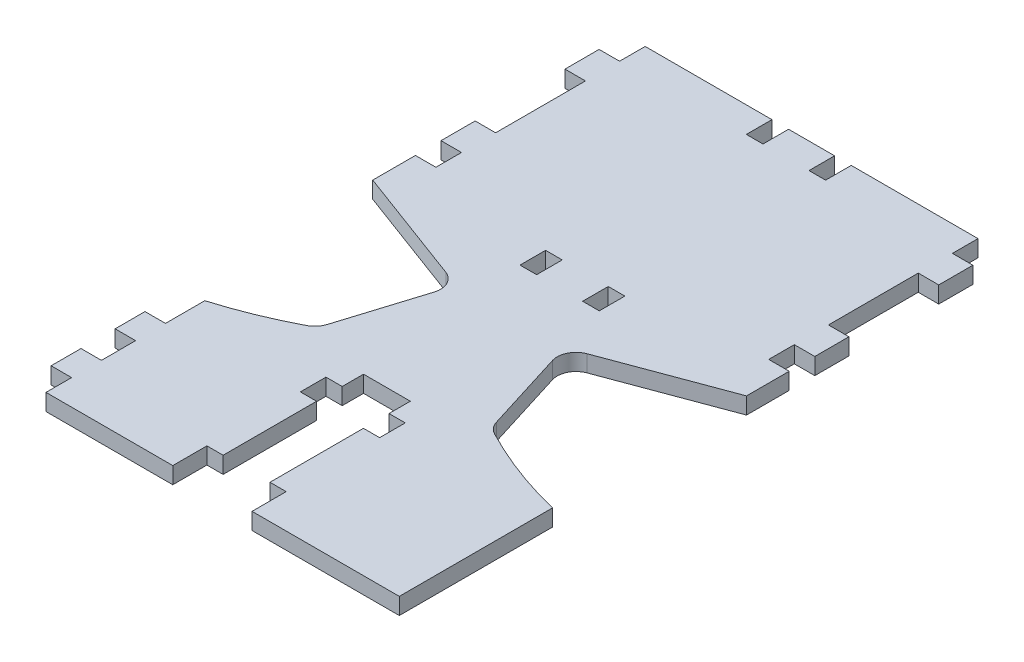
from build123d import *

# Parameters (mm, degrees)
SKETCH1_W           = 4.953
SKETCH1_H           = 7.62
BOSS_EXTRUDE1_DEPTH = 2.4765


with BuildPart() as part:
    # Sketch1 → Boss-Extrude1 (new, symmetric)
    with BuildSketch(Plane(origin=(0, 0, 0), x_dir=(1, 0, 0), z_dir=(0, 1, 0))):
        with BuildLine():
            Line((-49.53, 45.72), (-11.7983, 45.72))
            Line((-11.7983, 45.72), (-11.7983, 38.1))
            Line((-11.7983, 38.1), (-6.8453, 38.1))
            Line((-6.8453, 38.1), (-6.8453, 45.72))
            Line((-6.8453, 45.72), (6.8453, 45.72))
            Line((6.8453, 45.72), (6.8453, 38.1))
            Line((6.8453, 38.1), (11.7983, 38.1))
            Line((11.7983, 38.1), (11.7983, 45.72))
            Line((11.7983, 45.72), (49.53, 45.72))
            Line((49.53, 45.72), (49.53, 38.1))
            Line((49.53, 38.1), (55.626, 38.1))
            Line((55.626, 38.1), (55.626, 27.94))
            Line((55.626, 27.94), (49.53, 27.94))
            Line((49.53, 27.94), (49.53, 1.208143374))
            Line((49.53, 1.208143374), (55.626, 1.208143374))
            Line((55.626, 1.208143374), (55.626, -8.951856626))
            Line((55.626, -8.951856626), (49.53, -8.951856626))
            Line((49.53, -8.951856626), (49.53, -16.571856626))
            Line((49.53, -16.571856626), (55.626, -16.571856626))
            Line((55.626, -16.571856626), (55.626, -29.271856626))
            Line((55.626, -29.271856626), (21.019827136, -42.136821893))
            ThreePointArc((21.019827136, -42.136821893), (17.95098831, -44.911778638), (17.631953735, -49.036869377))
            Line((17.631953735, -49.036869377), (25.187729856, -73.287029113))
            ThreePointArc((25.187729856, -73.287029113), (26.234780075, -75.207903536), (27.939063878, -76.579577488))
            ThreePointArc((27.939063878, -76.579577488), (41.468907088, -82.632484358), (55.626, -87.022365809))
            Line((55.626, -87.022365809), (55.626, -132.617292876))
            Line((55.626, -132.617292876), (11.7983, -132.617292876))
            Line((11.7983, -132.617292876), (11.7983, -122.457292876))
            Line((11.7983, -122.457292876), (6.9723, -122.457292876))
            Line((6.9723, -122.457292876), (6.9723, -94.642365809))
            Line((6.9723, -94.642365809), (11.7983, -94.642365809))
            Line((11.7983, -94.642365809), (11.7983, -87.022365809))
            Line((11.7983, -87.022365809), (6.9723, -87.022365809))
            Line((6.9723, -87.022365809), (6.9723, -80.672365809))
            Line((6.9723, -80.672365809), (-6.9723, -80.672365809))
            Line((-6.9723, -80.672365809), (-6.9723, -87.022365809))
            Line((-6.9723, -87.022365809), (-11.7983, -87.022365809))
            Line((-11.7983, -87.022365809), (-11.7983, -94.642365809))
            Line((-11.7983, -94.642365809), (-6.9723, -94.642365809))
            Line((-6.9723, -94.642365809), (-6.9723, -122.457292876))
            Line((-6.9723, -122.457292876), (-11.7983, -122.457292876))
            Line((-11.7983, -122.457292876), (-11.7983, -132.617292876))
            Line((-11.7983, -132.617292876), (-49.53, -132.617292876))
            Line((-49.53, -132.617292876), (-49.53, -124.997292876))
            Line((-49.53, -124.997292876), (-55.626, -124.997292876))
            Line((-55.626, -124.997292876), (-55.626, -116.107292876))
            Line((-55.626, -116.107292876), (-49.53, -116.107292876))
            Line((-49.53, -116.107292876), (-49.53, -105.947292876))
            Line((-49.53, -105.947292876), (-55.626, -105.947292876))
            Line((-55.626, -105.947292876), (-55.626, -97.057292876))
            Line((-55.626, -97.057292876), (-49.53, -97.057292876))
            Line((-49.53, -97.057292876), (-49.53, -85.359826344))
            ThreePointArc((-49.53, -85.359826344), (-38.527111219, -81.479756652), (-27.939063878, -76.579577488))
            ThreePointArc((-27.939063878, -76.579577488), (-26.234780075, -75.207903536), (-25.187729856, -73.287029113))
            Line((-25.187729856, -73.287029113), (-17.631953735, -49.036869377))
            ThreePointArc((-17.631953735, -49.036869377), (-17.95098831, -44.911778638), (-21.019827136, -42.136821893))
            Line((-21.019827136, -42.136821893), (-55.626, -29.271856626))
            Line((-55.626, -29.271856626), (-55.626, -16.571856626))
            Line((-55.626, -16.571856626), (-49.53, -16.571856626))
            Line((-49.53, -16.571856626), (-49.53, -8.951856626))
            Line((-49.53, -8.951856626), (-55.626, -8.951856626))
            Line((-55.626, -8.951856626), (-55.626, 1.208143374))
            Line((-55.626, 1.208143374), (-49.53, 1.208143374))
            Line((-49.53, 1.208143374), (-49.53, 27.94))
            Line((-49.53, 27.94), (-55.626, 27.94))
            Line((-55.626, 27.94), (-55.626, 38.1))
            Line((-55.626, 38.1), (-49.53, 38.1))
            Line((-49.53, 38.1), (-49.53, 45.72))
        make_face()
        with Locations((9.3218, -25.461856626)):
            Rectangle(SKETCH1_W, SKETCH1_H, mode=Mode.SUBTRACT)
        with Locations((-9.3218, -25.461856626)):
            Rectangle(SKETCH1_W, SKETCH1_H, mode=Mode.SUBTRACT)
    extrude(amount=BOSS_EXTRUDE1_DEPTH, both=True)


solid = part.part
